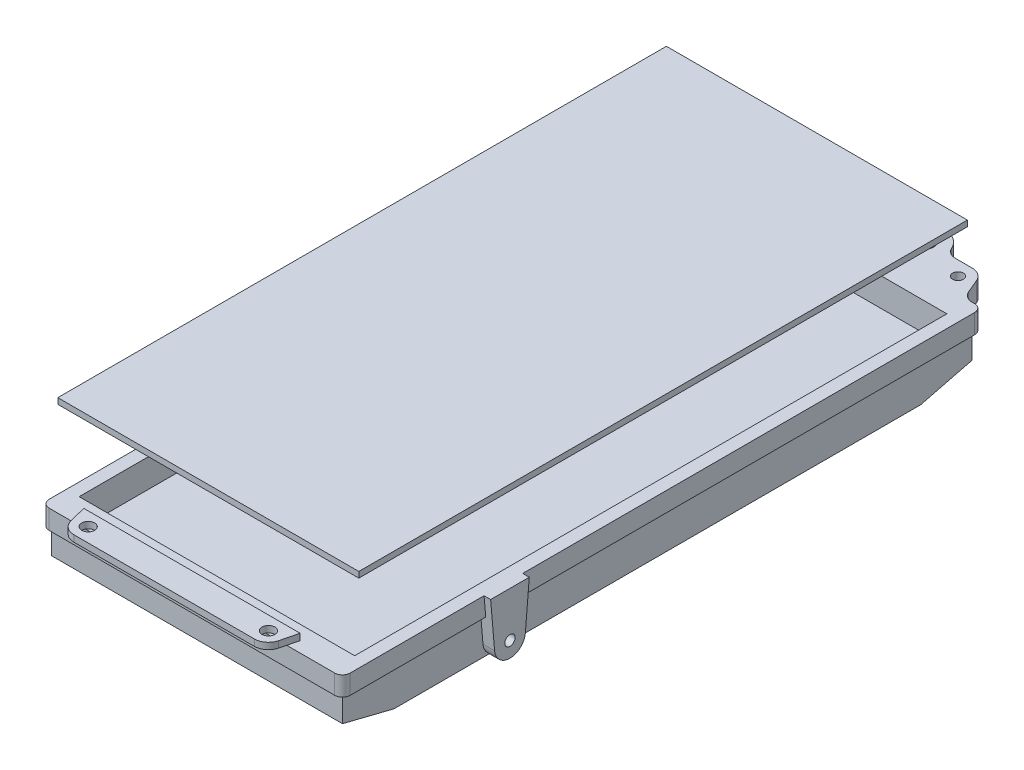
from build123d import *

# Parameters (mm, degrees)
SKETCH_2_R          = 3.5
SKETCH_2_R_2        = 1.75
EXTRUDE_1_DEPTH     = 7.5
SKETCH_3_R          = 5.25
CUT_EXTRUDE_1_DEPTH = 4
HOLE_WIZARD_M5_1_D  = 4.2
SKETCH_6_W          = 113
SKETCH_6_H          = 244.55
EXTRUDE_2_DEPTH     = 15
SKETCH_7_R          = 2
EXTRUDE_4_DEPTH     = 4.5
EXTRUDE_START       = -113
SKETCH_7_4_R        = 2
EXTRUDE_5_DEPTH     = 4.5
SKETCH_8_W          = 10.8
SKETCH_8_H          = 2.5
EXTRUDE_6_DEPTH     = 110
CUT_EXTRUDE_2_DEPTH = 110
SKETCH_11_W         = 2.5
SKETCH_11_H         = 30.16
MM_1_AT_2_COUNT     = 2
MM_1_AT_2_PITCH     = 70
CUT_EXTRUDE_3_DEPTH = 118.5
SKETCH_13_W         = 236.353812636
SKETCH_13_H         = 2.262628903
EXTRUDE_7_DEPTH     = 116.9
CUT_EXTRUDE_4_DEPTH = 11


with BuildPart() as part:
    # 草图2 → 凸台-拉伸1 (new body)
    with BuildSketch(Plane(origin=(0, 0, 0), x_dir=(1, 0, 0), z_dir=(0, 1, 0))):
        with BuildLine():
            Line((-43, 135.75), (-36.456439237, 135.75))
            ThreePointArc((-36.456439237, 135.75), (-33.991687729, 136.485029881), (-32.332121112, 138.45))
            ThreePointArc((-32.332121112, 138.45), (-25, 143.25), (-17.667878888, 138.45))
            ThreePointArc((-17.667878888, 138.45), (-16.008312271, 136.485029881), (-13.543560763, 135.75))
            Line((-13.543560763, 135.75), (13.543560763, 135.75))
            ThreePointArc((13.543560763, 135.75), (16.008312271, 136.485029881), (17.667878888, 138.45))
            ThreePointArc((17.667878888, 138.45), (25, 143.25), (32.332121112, 138.45))
            ThreePointArc((32.332121112, 138.45), (33.991687729, 136.485029881), (36.456439237, 135.75))
            Line((36.456439237, 135.75), (43, 135.75))
            ThreePointArc((43, 135.75), (46.040865614, 134.832917882), (48.067649964, 132.387504115))
            Line((48.067649964, 132.387504115), (50.339588736, 127.001132996))
            ThreePointArc((50.339588736, 127.001132996), (51.99786684, 125.000339914), (54.485847797, 124.25))
            Line((54.485847797, 124.25), (55.45, 124.25))
            ThreePointArc((55.45, 124.25), (57.571320344, 123.371320344), (58.45, 121.25))
            Line((58.45, 121.25), (58.45, -121.25))
            ThreePointArc((58.45, -121.25), (57.571320344, -123.371320344), (55.45, -124.25))
            Line((55.45, -124.25), (-55.45, -124.25))
            ThreePointArc((-55.45, -124.25), (-57.571320344, -123.371320344), (-58.45, -121.25))
            Line((-58.45, -121.25), (-58.45, 121.25))
            ThreePointArc((-58.45, 121.25), (-57.571320344, 123.371320344), (-55.45, 124.25))
            Line((-55.45, 124.25), (-54.485847797, 124.25))
            ThreePointArc((-54.485847797, 124.25), (-51.99786684, 125.000339914), (-50.339588736, 127.001132996))
            Line((-50.339588736, 127.001132996), (-48.067649964, 132.387504115))
            ThreePointArc((-48.067649964, 132.387504115), (-46.040865614, 134.832917882), (-43, 135.75))
        make_face()
        with Locations((-25, 135.25)):
            Circle(SKETCH_2_R, mode=Mode.SUBTRACT)
        with Locations((25, 135.25)):
            Circle(SKETCH_2_R, mode=Mode.SUBTRACT)
        with Locations((-43, 130.25)):
            Circle(SKETCH_2_R_2, mode=Mode.SUBTRACT)
        with Locations((43, 130.25)):
            Circle(SKETCH_2_R_2, mode=Mode.SUBTRACT)
    extrude(amount=EXTRUDE_1_DEPTH)

    # 草图3 → 切除-拉伸1 (cut)
    with BuildSketch(Plane.XZ):
        with Locations((25, -135.25)):
            Circle(SKETCH_3_R)
        with Locations((-25, -135.25)):
            Circle(SKETCH_3_R)
    extrude(amount=-CUT_EXTRUDE_1_DEPTH, mode=Mode.SUBTRACT)

    # M5 螺纹孔1 (through all)
    with Locations(Plane(origin=(0, 7.5, 0), x_dir=(1, 0, 0), z_dir=(0, 1, 0))):
        with Locations((-43, 130.25), (43, 130.25)):
            Hole(HOLE_WIZARD_M5_1_D / 2)

    # 草图6 → 凸台-拉伸2 (add)
    with BuildSketch(Plane.XZ):
        with Locations((0, 0.025)):
            Rectangle(SKETCH_6_W, SKETCH_6_H)
    extrude(amount=EXTRUDE_2_DEPTH)

    # 草图7 → 凸台-拉伸4 (add)
    with BuildSketch(Plane.ZY.offset(56.5)):
        with BuildLine():
            Line((68.616305254, 0), (54.883694746, 0))
            Line((54.883694746, 0), (55.771303021, -10.505155848))
            ThreePointArc((55.771303021, -10.505155848), (61.497197582, -4.005328121), (67.75, -10))
            ThreePointArc((67.75, -10), (67.744671879, -10.252802418), (67.728696979, -10.505155848))
            Line((67.728696979, -10.505155848), (68.616305254, 0))
        make_face()
        with BuildLine():
            ThreePointArc((67.75, -10), (61.497197582, -4.005328121), (55.771303021, -10.505155848))
            ThreePointArc((55.771303021, -10.505155848), (56.587475648, -13.057505897), (58.43337521, -15))
            Line((58.43337521, -15), (65.06662479, -15))
            ThreePointArc((65.06662479, -15), (66.912524352, -13.057505897), (67.728696979, -10.505155848))
            ThreePointArc((67.728696979, -10.505155848), (67.744671879, -10.252802418), (67.75, -10))
        make_face()
        with Locations((61.75, -10)):
            Circle(SKETCH_7_R, mode=Mode.SUBTRACT)
        Polygon((69.25, 7.5), (54.25, 7.5), (54.883694746, 0), (68.616305254, 0), align=None)
        with BuildLine():
            Line((65.06662479, -15), (58.43337521, -15))
            ThreePointArc((58.43337521, -15), (61.75, -16), (65.06662479, -15))
        make_face()
    extrude(amount=EXTRUDE_4_DEPTH)

    # 草图7<4> → 凸台-拉伸5 (add)
    with BuildSketch(Plane.ZY.offset(56.5).offset(EXTRUDE_START)):
        with BuildLine():
            Line((68.616305254, 0), (54.883694746, 0))
            Line((54.883694746, 0), (55.771303021, -10.505155848))
            ThreePointArc((55.771303021, -10.505155848), (61.497197582, -4.005328121), (67.75, -10))
            ThreePointArc((67.75, -10), (67.744671879, -10.252802418), (67.728696979, -10.505155848))
            Line((67.728696979, -10.505155848), (68.616305254, 0))
        make_face()
        with BuildLine():
            ThreePointArc((67.75, -10), (61.497197582, -4.005328121), (55.771303021, -10.505155848))
            ThreePointArc((55.771303021, -10.505155848), (56.587475648, -13.057505897), (58.43337521, -15))
            Line((58.43337521, -15), (65.06662479, -15))
            ThreePointArc((65.06662479, -15), (66.912524352, -13.057505897), (67.728696979, -10.505155848))
            ThreePointArc((67.728696979, -10.505155848), (67.744671879, -10.252802418), (67.75, -10))
        make_face()
        with Locations((61.75, -10)):
            Circle(SKETCH_7_4_R, mode=Mode.SUBTRACT)
        Polygon((69.25, 7.5), (54.25, 7.5), (54.883694746, 0), (68.616305254, 0), align=None)
        with BuildLine():
            Line((65.06662479, -15), (58.43337521, -15))
            ThreePointArc((58.43337521, -15), (61.75, -16), (65.06662479, -15))
        make_face()
    extrude(amount=-EXTRUDE_5_DEPTH)

    # 草图12 → 切除-拉伸3 (cut, through all)
    with BuildSketch(Plane.ZY.offset(56.5)):
        Polygon((122.3, -10), (102.3, -15), (122.3, -15), align=None)
        Polygon((-102.25, -15), (-122.25, -10), (-122.25, -15), align=None)
    extrude(amount=-CUT_EXTRUDE_3_DEPTH, mode=Mode.SUBTRACT)

    # 草图14 → 切除-拉伸4 (cut)
    with BuildSketch(Plane(origin=(0, 7.5, 0), x_dir=(1, 0, 0), z_dir=(0, 1, 0))):
        Polygon((-53.5, -114.559708527), (53.5, -114.559708527), (53.5, -102.3), (53.5, -65.06662479), (53.5, -58.43337521), (53.5, 102.25), (53.5, 115.440291473), (-53.5, 115.440291473), (-53.5, 102.25), (-53.5, -58.43337521), (-53.5, -65.06662479), (-53.5, -102.3), align=None)
    extrude(amount=-CUT_EXTRUDE_4_DEPTH, mode=Mode.SUBTRACT)


with BuildPart() as body_2:
    # 草图8 → 凸台-拉伸6 (new body)
    with BuildSketch(Plane.ZY.offset(58.45)):
        with Locations((129.65, 12.91)):
            Rectangle(SKETCH_8_W, SKETCH_8_H)
    extrude(amount=-EXTRUDE_6_DEPTH)

    # 草图9 → 切除-拉伸2 (cut)
    with BuildSketch(Plane(origin=(0, 14.16, 0), x_dir=(1, 0, 0), z_dir=(0, 1, 0))):
        with BuildLine():
            Line((-40.334698203, -130.888280645), (-42, -124.25))
            Line((-42, -124.25), (-58.45, -124.25))
            Line((-58.45, -124.25), (-58.45, -135.05))
            Line((-58.45, -135.05), (-35, -135.05))
            ThreePointArc((-35, -135.05), (-38.383005797, -133.886504557), (-40.334698203, -130.888280645))
        make_face()
        with BuildLine():
            ThreePointArc((40.334698203, -130.888280645), (38.383005797, -133.886504557), (35, -135.05))
            Line((35, -135.05), (51.55, -135.05))
            Line((51.55, -135.05), (51.55, -124.25))
            Line((51.55, -124.25), (42, -124.25))
            Line((42, -124.25), (40.334698203, -130.888280645))
        make_face()
    extrude(amount=-CUT_EXTRUDE_2_DEPTH, mode=Mode.SUBTRACT)

    # 草图11 → 大小mm 暗销孔1 (revolve, cut)
    with BuildSketch(Plane(origin=(-35, 14.16, 129.55), x_dir=(0, 0, 1), z_dir=(1, 0, 0))):
        with Locations((1.25, 15.08)):
            Rectangle(SKETCH_11_W, SKETCH_11_H)
    mm_1 = revolve(axis=Axis((-35, 20.51, 129.55), (0, -1, 0)), mode=Mode.SUBTRACT)

    # 大小mm 暗销孔1 at 2: 大小mm 暗销孔1 ×2
    with Locations(*[(i * MM_1_AT_2_PITCH, 0, 0) for i in range(1, MM_1_AT_2_COUNT)]):
        add(mm_1, mode=Mode.SUBTRACT)


with BuildPart() as body_3:
    # 草图13 → 凸台-拉伸7 (new body)
    with BuildSketch(Plane(origin=(58.45, 0, 0), x_dir=(0, 0, -1), z_dir=(1, 0, 0))):
        with Locations((0.278358751, 38.868685548)):
            Rectangle(SKETCH_13_W, SKETCH_13_H)
    extrude(amount=-EXTRUDE_7_DEPTH)


solid = Compound([part.part, body_2.part, body_3.part])
